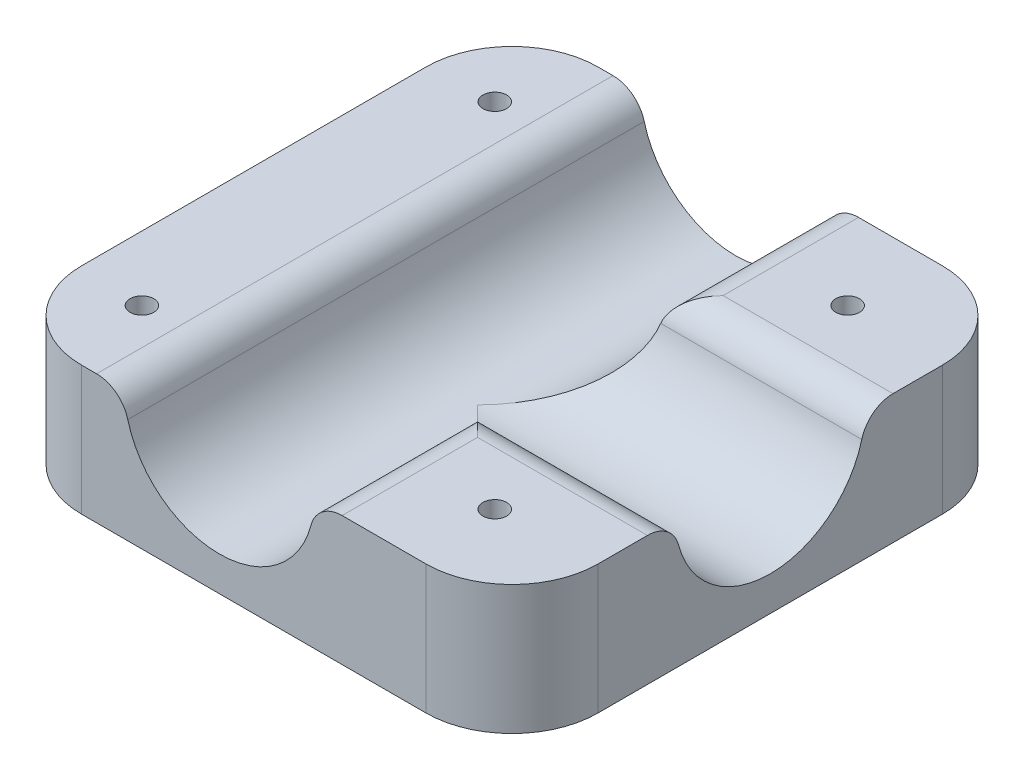
from build123d import *

# Parameters (mm, degrees)
SKETCH1_W           = 19.05
SKETCH1_H           = 76.2
SKETCH1_R           = 1.75
SKETCH1_W_2         = 29.21
SKETCH1_H_2         = 24.13
SKETCH1_H_3         = 27.94
BOSS_EXTRUDE2_DEPTH = 19.05
SKETCH3_R           = 13.97
CUT_EXTRUDE2_DEPTH  = 77.2
CUT_EXTRUDE3_REACH  = 78.2
SKETCH4_R           = 13.97
FILLET1_R           = 4.7625
FILLET2_R           = 12.7


with BuildPart() as part:
    # Sketch1 → Boss-Extrude2 (new body)
    with BuildSketch(Plane(origin=(0, 0, 0), x_dir=(1, 0, 0), z_dir=(0, 1, 0))):
        with Locations((9.525, 38.1)):
            Rectangle(SKETCH1_W, SKETCH1_H)
        with Locations((9.525, 12.065)):
            Circle(SKETCH1_R, mode=Mode.SUBTRACT)
        with Locations((9.525, 64.135)):
            Circle(SKETCH1_R, mode=Mode.SUBTRACT)
        Polygon((19.05, 76.2), (19.05, 0), (46.99, 0), (46.99, 24.13), (46.99, 52.07), (46.99, 76.2), align=None)
        with Locations((61.595, 64.135)):
            Rectangle(SKETCH1_W_2, SKETCH1_H_2)
        with Locations((61.595, 64.135)):
            Circle(SKETCH1_R, mode=Mode.SUBTRACT)
        with Locations((61.595, 38.1)):
            Rectangle(SKETCH1_W_2, SKETCH1_H_3)
        with Locations((61.595, 12.065)):
            Rectangle(SKETCH1_W_2, SKETCH1_H_2)
        with Locations((61.595, 12.065)):
            Circle(SKETCH1_R, mode=Mode.SUBTRACT)
    extrude(amount=BOSS_EXTRUDE2_DEPTH)

    # Sketch3 → Cut-Extrude2 (cut, through all)
    with BuildSketch(Plane.XY):
        with Locations((33.02, 19.05)):
            Circle(SKETCH3_R)
    extrude(amount=-CUT_EXTRUDE2_DEPTH, mode=Mode.SUBTRACT)

    # Sketch4 → Cut-Extrude3 (cut, up to next)
    with BuildSketch(Plane(origin=(76.2, 0, 0), x_dir=(0, 0, -1), z_dir=(1, 0, 0)), mode=Mode.PRIVATE) as cut_extrude3_sk1:
        with Locations((38.1, 19.05)):
            Circle(SKETCH4_R)
    cut_extrude3_tool1 = extrude(cut_extrude3_sk1.sketch, amount=-CUT_EXTRUDE3_REACH, mode=Mode.PRIVATE) & part.part
    add(cut_extrude3_tool1.solids().sort_by_distance((76.2, 19.05, -38.1))[0], mode=Mode.SUBTRACT)

    # Fillet1
    fillet1_edges = [part.edges().sort_by_distance(p)[0] for p in [
        (46.99, 19.05, -12.065),
        (61.595, 19.05, -24.13),
        (61.595, 19.05, -52.07),
        (46.99, 19.05, -64.135),
        (19.05, 19.05, -38.1),
    ]]
    fillet(fillet1_edges, radius=FILLET1_R)

    # Fillet2
    fillet2_edges = [part.edges().sort_by_distance(p)[0] for p in [
        (0, 9.525, 0),
        (0, 9.525, -76.2),
        (76.2, 9.525, -76.2),
        (76.2, 9.525, 0),
    ]]
    fillet(fillet2_edges, radius=FILLET2_R)


solid = part.part
